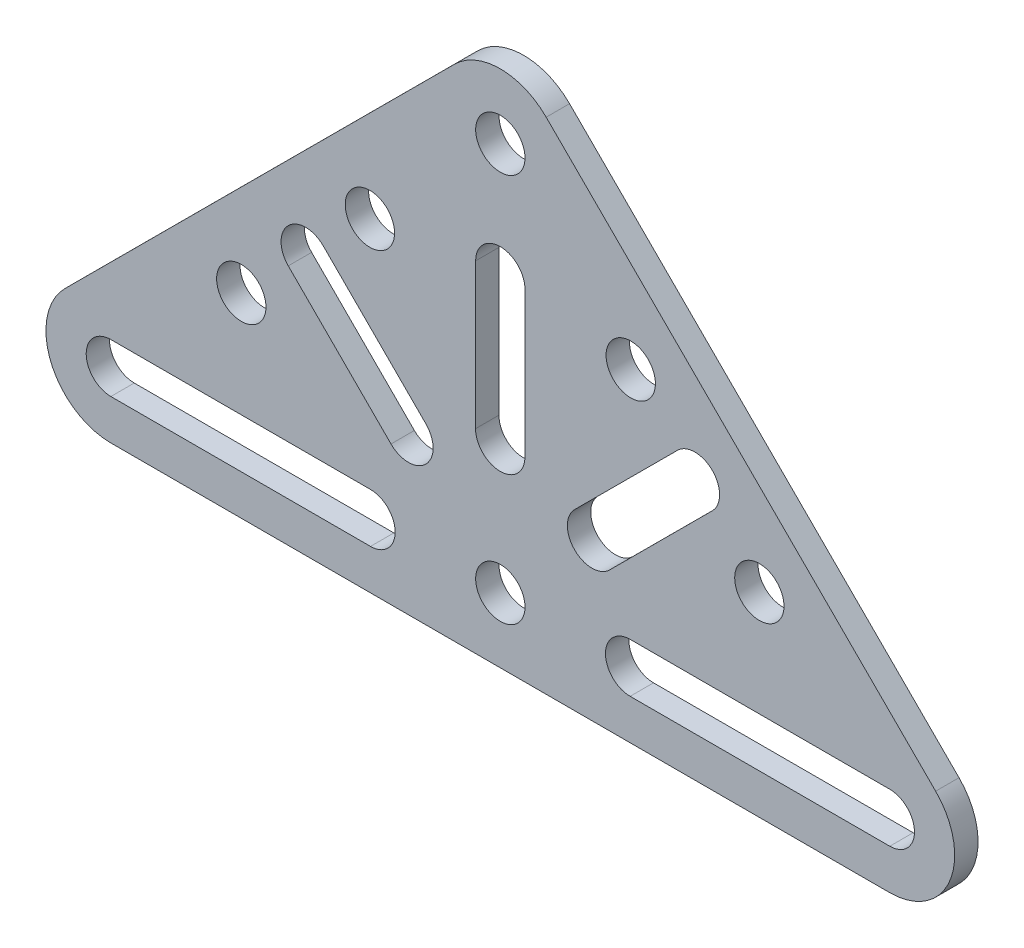
from build123d import *

# Parameters (mm, degrees)
BOSS_EXTRUDE1_DEPTH = 2.286
SKETCH2_R           = 2.413
CUT_EXTRUDE1_DEPTH  = 3.286
CUT_EXTRUDE2_DEPTH  = 3.286
CUT_EXTRUDE3_DEPTH  = 3.286
CIRPATTERN1_COUNT   = 3
CIRPATTERN1_ANGLE   = 90


with BuildPart() as part:
    # Sketch1 → Boss-Extrude1 (new body)
    with BuildSketch(Plane.XY):
        with BuildLine():
            Line((-42.58732985, 4.492924528), (-4.48732985, 42.545481657))
            ThreePointArc((-4.48732985, 42.545481657), (0, 44.402557128), (4.48732985, 42.545481657))
            Line((4.48732985, 42.545481657), (42.58732985, 4.492924528))
            ThreePointArc((42.58732985, 4.492924528), (43.967391701, -2.428212228), (38.1, -6.35))
            Line((38.1, -6.35), (-38.1, -6.35))
            ThreePointArc((-38.1, -6.35), (-43.967391701, -2.428212228), (-42.58732985, 4.492924528))
        make_face()
    extrude(amount=BOSS_EXTRUDE1_DEPTH)

    # Sketch2 → Cut-Extrude1 (cut, through all)
    with BuildSketch(Plane.XY.offset(2.286)):
        Circle(SKETCH2_R)
        with Locations((0, 38.052557128)):
            Circle(SKETCH2_R)
        with Locations((-25.34009434, 12.744016774)):
            Circle(SKETCH2_R)
        with Locations((25.34009434, 12.744016774)):
            Circle(SKETCH2_R)
        with Locations((-12.75990566, 25.308540354)):
            Circle(SKETCH2_R)
        with Locations((12.75990566, 25.308540354)):
            Circle(SKETCH2_R)
    extrude(amount=-CUT_EXTRUDE1_DEPTH, mode=Mode.SUBTRACT)

    # Sketch3 → Cut-Extrude2 (cut, through all)
    with BuildSketch(Plane.XY.offset(2.286)):
        with BuildLine():
            Line((-38.1, 2.413), (-12.7, 2.413))
            ThreePointArc((-12.7, 2.413), (-10.287, 0), (-12.7, -2.413))
            Line((-12.7, -2.413), (-38.1, -2.413))
            ThreePointArc((-38.1, -2.413), (-40.513, 0), (-38.1, 2.413))
        make_face()
    cut_extrude2 = extrude(amount=-CUT_EXTRUDE2_DEPTH, mode=Mode.SUBTRACT)

    # Mirror1: Cut-Extrude2 across plane
    add(cut_extrude2.mirror(Plane(origin=(0, 0, 0), x_dir=(0, 0, 1), z_dir=(1, 0, 0))), mode=Mode.SUBTRACT)

    # Sketch4 → Cut-Extrude3 (cut, through all)
    with BuildSketch(Plane.XY.offset(2.286)):
        with BuildLine():
            Line((-20.745443214, 17.33294655), (-10.69382435, 7.268795606))
            ThreePointArc((-10.69382435, 7.268795606), (-7.281327686, 7.266669629), (-7.279201708, 10.679166292))
            Line((-7.279201708, 10.679166292), (-17.330820572, 20.743317236))
            ThreePointArc((-17.330820572, 20.743317236), (-20.743317236, 20.745443214), (-20.745443214, 17.33294655))
        make_face()
    cut_extrude3 = extrude(amount=-CUT_EXTRUDE3_DEPTH, mode=Mode.SUBTRACT)

    # CirPattern1: Cut-Extrude3 ×3 about axis
    cirpattern1_axis = Axis((0, 0, 0), (0, 0, -1))
    for i in range(1, CIRPATTERN1_COUNT):
        add(cut_extrude3.rotate(cirpattern1_axis, i * CIRPATTERN1_ANGLE / (CIRPATTERN1_COUNT - 1)), mode=Mode.SUBTRACT)


solid = part.part
